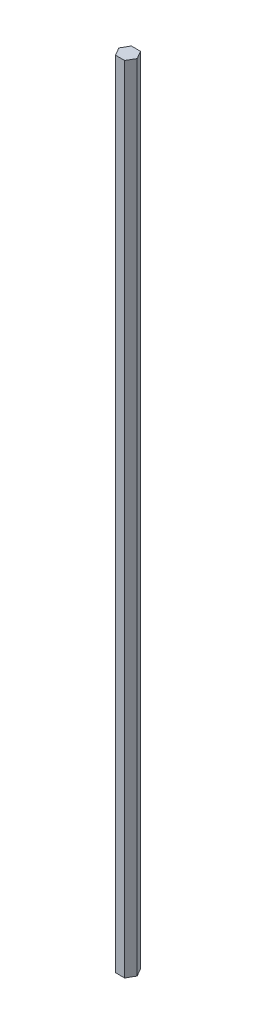
from build123d import *

# Parameters (mm, degrees)
BOSS_EXTRUDE1_DEPTH = 635


with BuildPart() as part:
    # Sketch1 → Boss-Extrude1 (new body)
    with BuildSketch(Plane(origin=(0, 0, 0), x_dir=(1, 0, 0), z_dir=(0, 1, 0))):
        Polygon((3.666174209, -6.35), (7.332348419, 0), (3.666174209, 6.35), (-3.666174209, 6.35), (-7.332348419, 0), (-3.666174209, -6.35), align=None)
    extrude(amount=BOSS_EXTRUDE1_DEPTH)


solid = part.part
